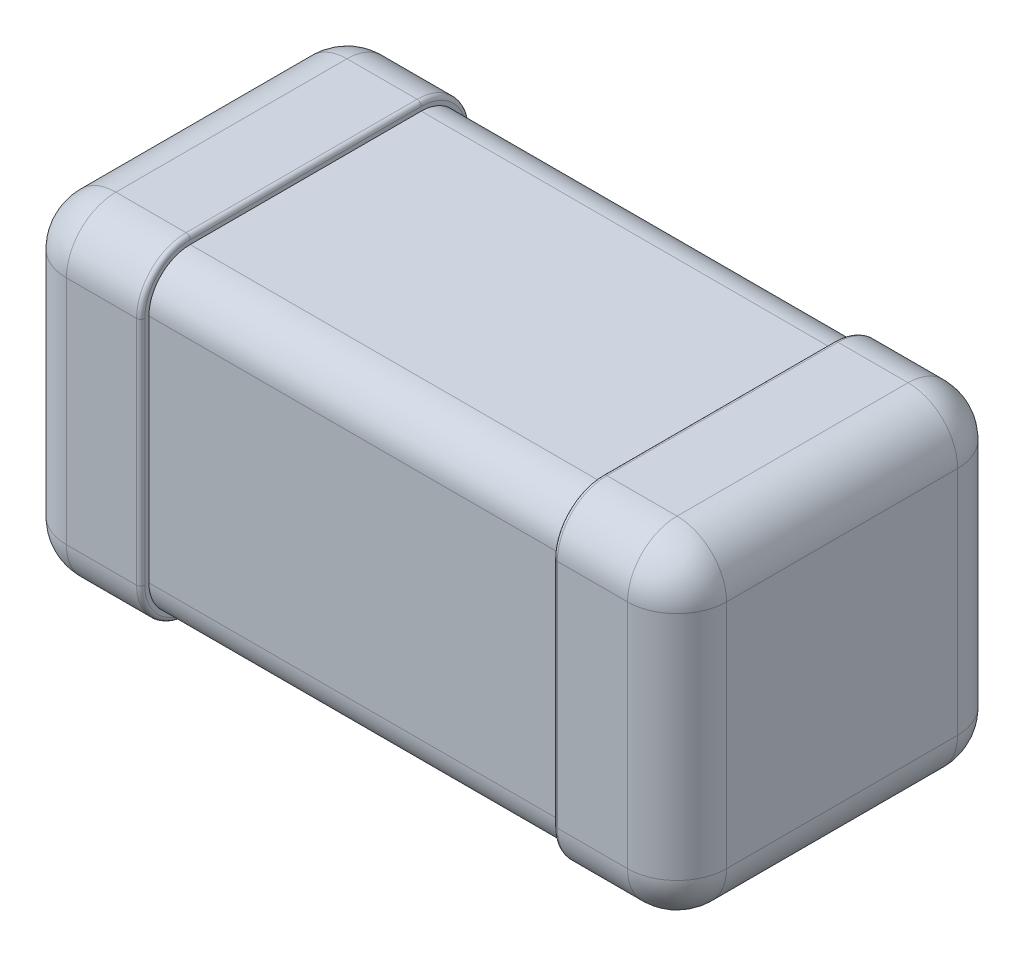
from build123d import *

# Parameters (mm, degrees)
SKETCH1_W               = 3.2
SKETCH1_H               = 1.6
BOSS_EXTRUDE1_DEPTH     = 0.8
SKETCH3_OUTSIDE_W       = 4.384
SKETCH3_OUTSIDE_H       = 4.384
SKETCH3_OUTSIDE_W_2     = 1.52
SKETCH3_OUTSIDE_H_2     = 1.52
CUT_EXTRUDE1_DEPTH      = 1
CUT_EXTRUDE1_DEPTH_BACK = 1
FILLET1_R               = 0.2
FILLET2_R               = 0.24
FILLET3_R               = 0.02


with BuildPart() as part:
    # Sketch1 → Boss-Extrude1 (new body, symmetric)
    with BuildSketch(Plane(origin=(0, 0, 0), x_dir=(1, 0, 0), z_dir=(0, 1, 0))):
        Rectangle(SKETCH1_W, SKETCH1_H)
    extrude(amount=BOSS_EXTRUDE1_DEPTH, both=True)

    # Sketch3 outside → Cut-Extrude1 (cut, two sides)
    with BuildSketch(Plane(origin=(0, 0, 0), x_dir=(0, 0, -1), z_dir=(1, 0, 0))) as cut_extrude1_sk:
        Rectangle(SKETCH3_OUTSIDE_W, SKETCH3_OUTSIDE_H)
        Rectangle(SKETCH3_OUTSIDE_W_2, SKETCH3_OUTSIDE_H_2, mode=Mode.SUBTRACT)
    extrude(amount=CUT_EXTRUDE1_DEPTH, mode=Mode.SUBTRACT)
    extrude(cut_extrude1_sk.sketch, amount=-CUT_EXTRUDE1_DEPTH_BACK, mode=Mode.SUBTRACT)

    # Fillet1
    fillet1_edges = [part.edges().sort_by_distance(p)[0] for p in [
        (0, -0.76, 0.76),
        (0, -0.76, -0.76),
        (0, 0.76, -0.76),
        (0, 0.76, 0.76),
    ]]
    fillet(fillet1_edges, radius=FILLET1_R)

    # Fillet2
    fillet2_edges = [part.edges().sort_by_distance(p)[0] for p in [
        (-1.6, 0.8, 0),
        (-1.3, 0.8, 0.8),
        (1.3, -0.8, 0.8),
        (-1.3, -0.8, -0.8),
        (-1.3, 0.8, -0.8),
        (1.3, 0.8, 0.8),
        (1.6, 0.8, 0),
        (-1.3, -0.8, 0.8),
        (-1.6, -0.8, 0),
        (1.3, -0.8, -0.8),
        (1.6, -0.8, 0),
        (1.3, 0.8, -0.8),
        (1.6, 0, 0.8),
        (-1.6, 0, 0.8),
        (-1.6, 0, -0.8),
        (1.6, 0, -0.8),
    ]]
    fillet(fillet2_edges, radius=FILLET2_R)

    # Fillet3
    fillet3_edges = [part.edges().sort_by_distance(p)[0] for p in [
        (1, 0, 0.8),
        (1, 0.8, 0),
        (1, 0, -0.8),
        (1, -0.8, 0),
        (-1, 0, -0.8),
        (-1, 0.8, 0),
        (-1, 0, 0.8),
        (-1, -0.8, 0),
        (-1, 0.729705627, -0.729705627),
        (-1, -0.729705627, -0.729705627),
        (-1, 0.729705627, 0.729705627),
        (-1, -0.729705627, 0.729705627),
        (1, -0.729705627, -0.729705627),
        (1, 0.729705627, -0.729705627),
        (1, -0.729705627, 0.729705627),
        (1, 0.729705627, 0.729705627),
    ]]
    fillet(fillet3_edges, radius=FILLET3_R)


solid = part.part
